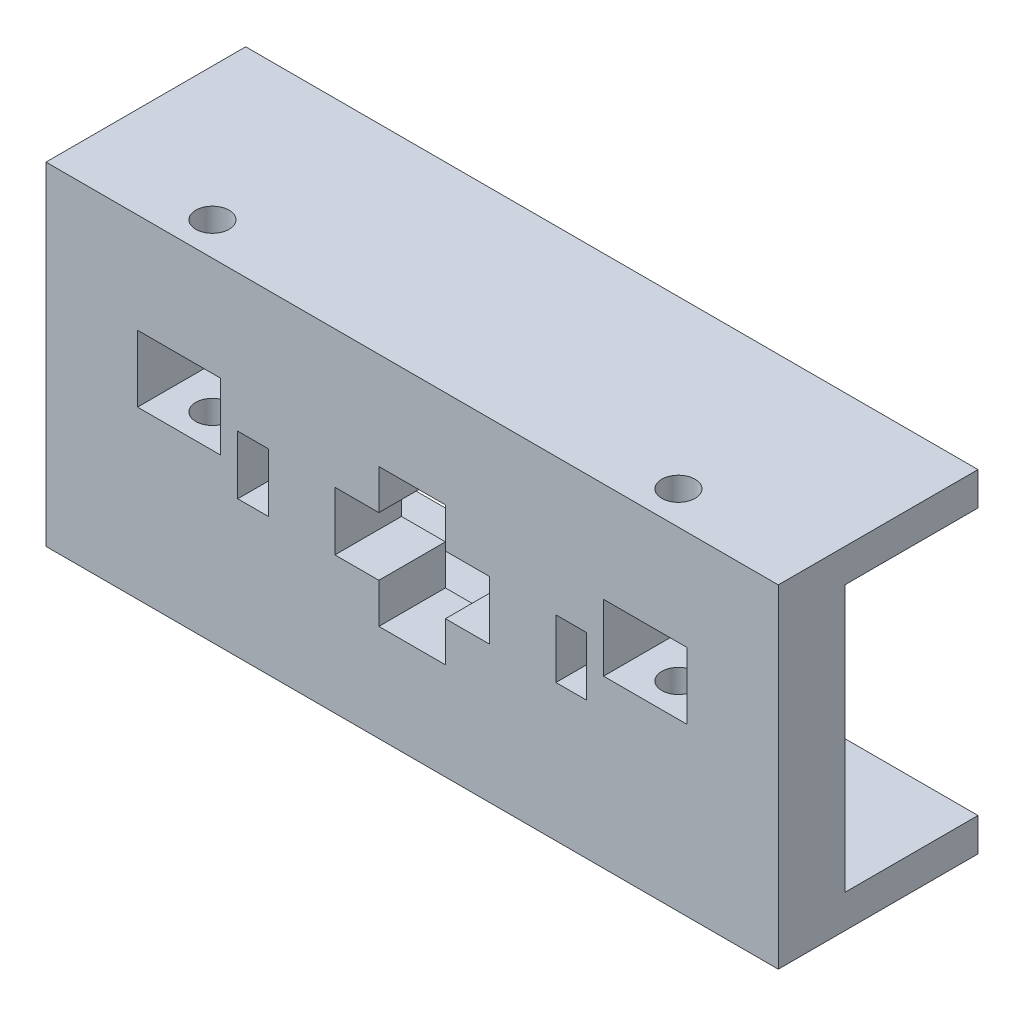
from build123d import *

# Parameters (mm, degrees)
BOSS_EXTRUDE1_DEPTH   = 12.7
BOSS_EXTRUDE1_2_DEPTH = 12.7
SKETCH1_3_W           = 69.85
SKETCH1_3_H           = 31.75
SKETCH1_3_W_2         = 2.921
SKETCH1_3_H_2         = 5.588
BOSS_EXTRUDE2_DEPTH   = 6.35
SKETCH3_R             = 1.5875
CUT_EXTRUDE1_DEPTH    = 20.32
SKETCH4_W             = 7.9375
SKETCH4_H             = 6.35
CUT_EXTRUDE2_DEPTH    = 6.35


with BuildPart() as part:
    # Sketch1 → Boss-Extrude1 (new body)
    with BuildSketch(Plane.XY):
        Polygon((-3.175, -13.6525), (-3.175, -12.7), (-34.925, -12.7), (-34.925, -15.875), (34.925, -15.875), (34.925, -12.7), (3.175, -12.7), (3.175, -13.6525), align=None)
    extrude(amount=-BOSS_EXTRUDE1_DEPTH)



with BuildPart() as body_2:
    # Sketch1 → Boss-Extrude1 2 (new body)
    with BuildSketch(Plane.XY):
        Polygon((-34.925, 15.875), (-34.925, 12.7), (-3.175, 12.7), (-3.175, 13.6525), (3.175, 13.6525), (3.175, 12.7), (34.925, 12.7), (34.925, 15.875), align=None)
    extrude(amount=-BOSS_EXTRUDE1_2_DEPTH)


with BuildPart() as part_1:
    add(part.part)

    add(body_2.part)  # Boss-Extrude2 merges body 2
    # Sketch1_3 → Boss-Extrude2 (add)
    with BuildSketch(Plane.XY):
        Rectangle(SKETCH1_3_W, SKETCH1_3_H)
        with Locations((15.1765, 0)):
            Rectangle(SKETCH1_3_W_2, SKETCH1_3_H_2, mode=Mode.SUBTRACT)
        with Locations((-15.1765, 0)):
            Rectangle(SKETCH1_3_W_2, SKETCH1_3_H_2, mode=Mode.SUBTRACT)
        Polygon((3.175, -6.604), (-3.175, -6.604), (-3.175, -2.794), (-7.366, -2.794), (-7.366, 2.794), (-3.175, 2.794), (-3.175, 6.604), (3.175, 6.604), (3.175, 2.794), (7.366, 2.794), (7.366, -2.794), (3.175, -2.794), align=None, mode=Mode.SUBTRACT)
    extrude(amount=BOSS_EXTRUDE2_DEPTH)

    # Sketch3 → Cut-Extrude1 (cut)
    with BuildSketch(Plane(origin=(0, 15.875, 0), x_dir=(1, 0, 0), z_dir=(0, 1, 0))):
        with Locations((22.225, -3.175)):
            Circle(SKETCH3_R)
        with Locations((-22.225, -3.175)):
            Circle(SKETCH3_R)
    extrude(amount=-CUT_EXTRUDE1_DEPTH, mode=Mode.SUBTRACT)

    # Sketch4 → Cut-Extrude2 (cut)
    with BuildSketch(Plane.XY.offset(6.35)):
        with Locations((-22.225, 3.175)):
            Rectangle(SKETCH4_W, SKETCH4_H)
        with Locations((22.225, 3.175)):
            Rectangle(SKETCH4_W, SKETCH4_H)
    extrude(amount=-CUT_EXTRUDE2_DEPTH, mode=Mode.SUBTRACT)


solid = part_1.part
